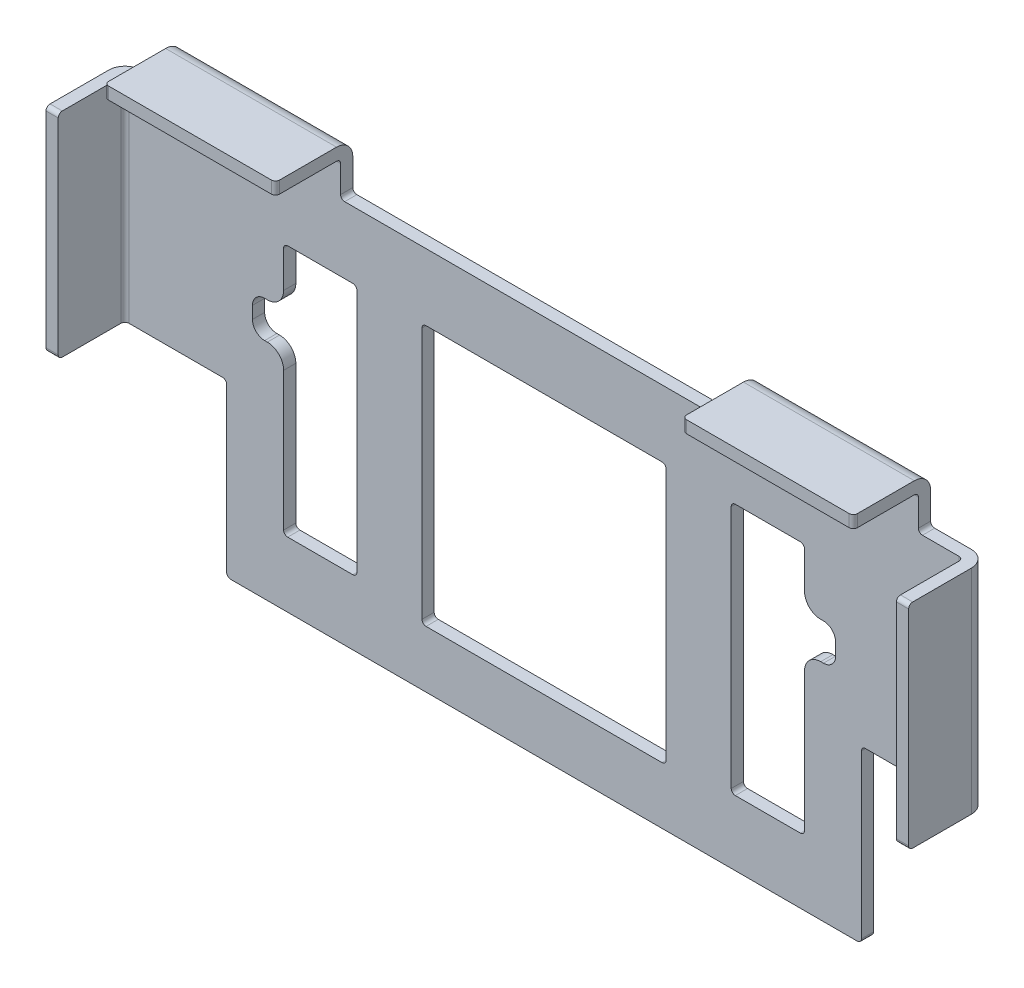
from build123d import *

# Parameters (mm, degrees)
SKETCH1_W           = 106
SKETCH1_H           = 26.2
BOSS_EXTRUDE1_DEPTH = 9.7
SKETCH2_W           = 103
SKETCH2_H           = 8.2
CUT_EXTRUDE1_DEPTH  = 27.2
SKETCH3_W           = 21
SKETCH3_H           = 1.5
BOSS_EXTRUDE2_DEPTH = 5.8
SKETCH4_W           = 21
SKETCH4_H           = 1.5
BOSS_EXTRUDE3_DEPTH = 8
SKETCH5_W           = 21
SKETCH5_H           = 1.5
BOSS_EXTRUDE4_DEPTH = 5.8
SKETCH6_W           = 21
SKETCH6_H           = 1.5
BOSS_EXTRUDE5_DEPTH = 8
SKETCH7_W           = 78
SKETCH7_H           = 1.5
BOSS_EXTRUDE6_DEPTH = 21
FILLET1_R           = 0.5
FILLET2_R           = 2
SKETCH8_W           = 30
SKETCH8_H           = 32
CUT_EXTRUDE2_DEPTH  = 1.5
FILLET4_R           = 2
FILLET5_R           = 1.5
FILLET6_R           = 0.5
FILLET7_R           = 0.5


with BuildPart() as part:
    # Sketch1 → Boss-Extrude1 (new body)
    with BuildSketch(Plane(origin=(0, 0, -42.5), x_dir=(-1, 0, 0), z_dir=(0, 0, -1))):
        with Locations((0, -2.9)):
            Rectangle(SKETCH1_W, SKETCH1_H)
    extrude(amount=-BOSS_EXTRUDE1_DEPTH)

    # Sketch2 → Cut-Extrude1 (cut, through all)
    with BuildSketch(Plane(origin=(0, 10.2, 0), x_dir=(-1, 0, 0), z_dir=(0, 1, 0))):
        with Locations((0, -36.9)):
            Rectangle(SKETCH2_W, SKETCH2_H)
    extrude(amount=-CUT_EXTRUDE1_DEPTH, mode=Mode.SUBTRACT)

    # Sketch3 → Boss-Extrude2 (add)
    with BuildSketch(Plane(origin=(0, 10.2, 0), x_dir=(-1, 0, 0), z_dir=(0, 1, 0))):
        with Locations((35.5, -41.75)):
            Rectangle(SKETCH3_W, SKETCH3_H)
    extrude(amount=BOSS_EXTRUDE2_DEPTH)

    # Sketch4 → Boss-Extrude3 (add)
    with BuildSketch(Plane.XY.offset(-41)):
        with Locations((-35.5, 15.25)):
            Rectangle(SKETCH4_W, SKETCH4_H)
    extrude(amount=BOSS_EXTRUDE3_DEPTH)

    # Sketch5 → Boss-Extrude4 (add)
    with BuildSketch(Plane(origin=(0, 10.2, 0), x_dir=(-1, 0, 0), z_dir=(0, 1, 0))):
        with Locations((-35.5, -41.75)):
            Rectangle(SKETCH5_W, SKETCH5_H)
    extrude(amount=BOSS_EXTRUDE4_DEPTH)

    # Sketch6 → Boss-Extrude5 (add)
    with BuildSketch(Plane.XY.offset(-41)):
        with Locations((35.5, 15.25)):
            Rectangle(SKETCH6_W, SKETCH6_H)
    extrude(amount=BOSS_EXTRUDE5_DEPTH)

    # Sketch7 → Boss-Extrude6 (add)
    with BuildSketch(Plane.XZ.offset(16)):
        with Locations((0, -41.75)):
            Rectangle(SKETCH7_W, SKETCH7_H)
    extrude(amount=BOSS_EXTRUDE6_DEPTH)

    # Fillet1
    fillet1_edges = [part.edges().sort_by_distance(p)[0] for p in [
        (-51.5, -2.9, -41),
        (51.5, -2.9, -41),
        (-35.5, 14.5, -41),
        (35.5, 14.5, -41),
    ]]
    fillet(fillet1_edges, radius=FILLET1_R)

    # Fillet2
    fillet2_edges = [part.edges().sort_by_distance(p)[0] for p in [
        (-35.5, 16, -42.5),
        (53, -2.9, -42.5),
        (-53, -2.9, -42.5),
        (35.5, 16, -42.5),
    ]]
    fillet(fillet2_edges, radius=FILLET2_R)

    # Sketch8 → Cut-Extrude2 (cut)
    with BuildSketch(Plane(origin=(0, 0, -42.5), x_dir=(-1, 0, 0), z_dir=(0, 0, -1))):
        with Locations((0, -14)):
            Rectangle(SKETCH8_W, SKETCH8_H)
        Polygon((-23, 2), (-32, 2), (-32, -5), (-35.831359268, -5), (-35.831359268, -9.5), (-32, -9.5), (-32, -29), (-23, -29), align=None)
        Polygon((32, -29), (23, -29), (23, 2), (32, 2), (32, -5), (35.831359268, -5), (35.831359268, -9.5), (32, -9.5), align=None)
    extrude(amount=-CUT_EXTRUDE2_DEPTH, mode=Mode.SUBTRACT)

    # Fillet4
    fillet4_edges = [part.edges().sort_by_distance(p)[0] for p in [
        (32, -9.5, -41.75),
        (32, -5, -41.75),
        (-32, -9.5, -41.75),
        (-32, -5, -41.75),
    ]]
    fillet(fillet4_edges, radius=FILLET4_R)

    # Fillet5
    fillet5_edges = [part.edges().sort_by_distance(p)[0] for p in [
        (35.831359268, -9.5, -41.75),
        (35.831359268, -5, -41.75),
        (-35.831359268, -5, -41.75),
        (-35.831359268, -9.5, -41.75),
    ]]
    fillet(fillet5_edges, radius=FILLET5_R)

    # Fillet6
    fillet6_edges = [part.edges().sort_by_distance(p)[0] for p in [
        (15, -30, -41.75),
        (15, 2, -41.75),
        (-15, 2, -41.75),
        (-15, -30, -41.75),
        (23, 2, -41.75),
        (23, -29, -41.75),
        (32, -29, -41.75),
        (32, 2, -41.75),
        (-32, -29, -41.75),
        (-23, -29, -41.75),
        (-23, 2, -41.75),
        (-32, 2, -41.75),
    ]]
    fillet(fillet6_edges, radius=FILLET6_R)

    # Fillet7
    fillet7_edges = [part.edges().sort_by_distance(p)[0] for p in [
        (52.25, -16, -32.8),
        (-52.25, -16, -32.8),
        (52.25, 10.2, -32.8),
        (-25, 10.2, -41.75),
        (-46, 10.2, -41.75),
        (-46, 15.25, -33),
        (-25, 15.25, -33),
        (46, 10.2, -41.75),
        (25, 10.2, -41.75),
        (-52.25, 10.2, -32.8),
        (46, 15.25, -33),
        (25, 15.25, -33),
        (-39, -16, -41.75),
        (39, -16, -41.75),
        (-39, -37, -41.75),
        (39, -37, -41.75),
    ]]
    fillet(fillet7_edges, radius=FILLET7_R)


solid = part.part
